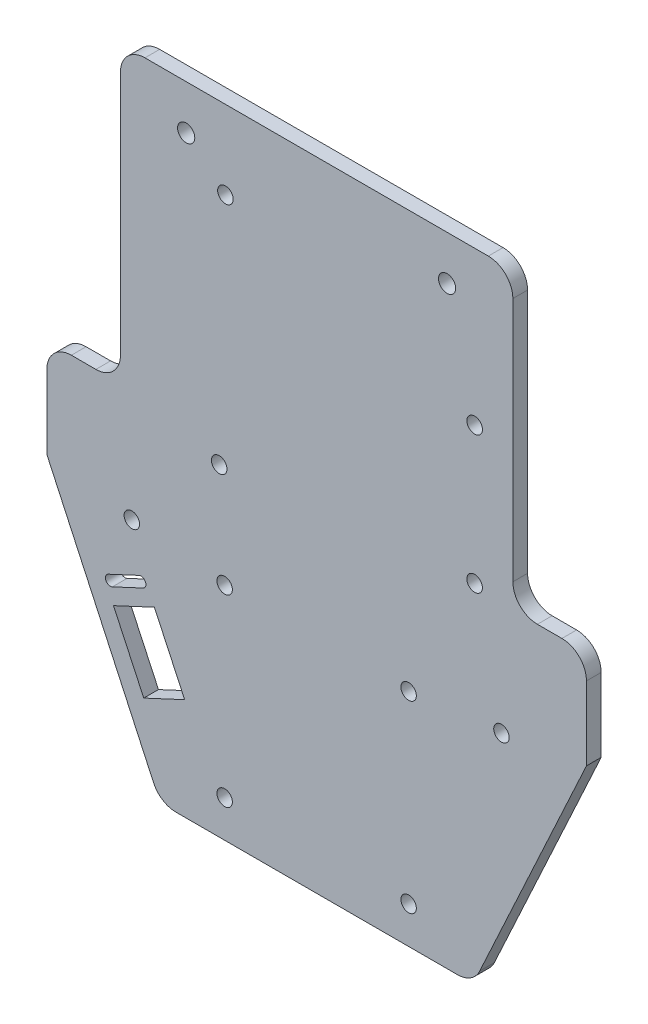
from build123d import *

# Parameters (mm, degrees)
SKETCH1_R           = 1.575
SKETCH1_R_2         = 1.5875
SKETCH1_R_3         = 1.75
BOSS_EXTRUDE1_DEPTH = 3
FILLET1_R           = 5


with BuildPart() as part:
    # Sketch1 → Boss-Extrude1 (new body)
    with BuildSketch(Plane.XY):
        with BuildLine():
            Line((-55, -3.774250665), (-33.235815946, -50.880076598))
            ThreePointArc((-33.235815946, -50.880076598), (-31.390782754, -52.995176633), (-28.696863862, -53.782956197))
            Line((-28.696863862, -53.782956197), (28.696863862, -53.782956197))
            ThreePointArc((28.696863862, -53.782956197), (31.390782754, -52.995176633), (33.235815946, -50.880076598))
            Line((33.235815946, -50.880076598), (55, -3.774250665))
            Line((55, -3.774250665), (55, 16.225749335))
            Line((55, 16.225749335), (40, 16.225749335))
            Line((40, 16.225749335), (40, 76.225749335))
            Line((40, 76.225749335), (-40, 76.225749335))
            Line((-40, 76.225749335), (-40, 16.225749335))
            Line((-40, 16.225749335), (-55, 16.225749335))
            Line((-55, 16.225749335), (-55, -3.774250665))
        make_face()
        with Locations((-37.673971089, -6.665090314)):
            Circle(SKETCH1_R, mode=Mode.SUBTRACT)
        with Locations((37.673971089, -6.665090314)):
            Circle(SKETCH1_R, mode=Mode.SUBTRACT)
        with Locations((32.208377558, 17.056918669)):
            Circle(SKETCH1_R_2, mode=Mode.SUBTRACT)
        with Locations((32.208377558, 44.996918669)):
            Circle(SKETCH1_R_2, mode=Mode.SUBTRACT)
        with Locations((-19.861622442, 11.976918669)):
            Circle(SKETCH1_R_2, mode=Mode.SUBTRACT)
        with Locations((-18.591622442, 60.236918669)):
            Circle(SKETCH1_R_2, mode=Mode.SUBTRACT)
        with Locations((-26.592001418, 67.180357374)):
            Circle(SKETCH1_R_3, mode=Mode.SUBTRACT)
        with Locations((26.592001418, 67.180357374)):
            Circle(SKETCH1_R_3, mode=Mode.SUBTRACT)
        with Locations((-18.75, -8.749633405)):
            Circle(SKETCH1_R, mode=Mode.SUBTRACT)
        with Locations((18.75, -8.749633405)):
            Circle(SKETCH1_R, mode=Mode.SUBTRACT)
        with Locations((-18.75, -46.249633405)):
            Circle(SKETCH1_R, mode=Mode.SUBTRACT)
        with Locations((18.75, -46.249633405)):
            Circle(SKETCH1_R, mode=Mode.SUBTRACT)
        Polygon((-41.411487692, -23.690735407), (-33.073456052, -19.802647399), (-26.90322943, -33.03474109), (-35.241261071, -36.922829098), align=None, mode=Mode.SUBTRACT)
        with BuildLine():
            Line((-41.63599241, -20.485289919), (-35.384660905, -17.570246165))
            ThreePointArc((-35.384660905, -17.570246165), (-34.90097138, -16.241320116), (-36.229897428, -15.757630591))
            Line((-36.229897428, -15.757630591), (-42.481228933, -18.672674345))
            ThreePointArc((-42.481228933, -18.672674345), (-42.964918459, -20.001600394), (-41.63599241, -20.485289919))
        make_face(mode=Mode.SUBTRACT)
    extrude(amount=BOSS_EXTRUDE1_DEPTH)

    # Fillet1
    fillet1_edges = [part.edges().sort_by_distance(p)[0] for p in [
        (-55, 16.225749335, 1.5),
        (-40, 16.225749335, 1.5),
        (-40, 76.225749335, 1.5),
        (40, 76.225749335, 1.5),
        (40, 16.225749335, 1.5),
        (55, 16.225749335, 1.5),
    ]]
    fillet(fillet1_edges, radius=FILLET1_R)


solid = part.part
